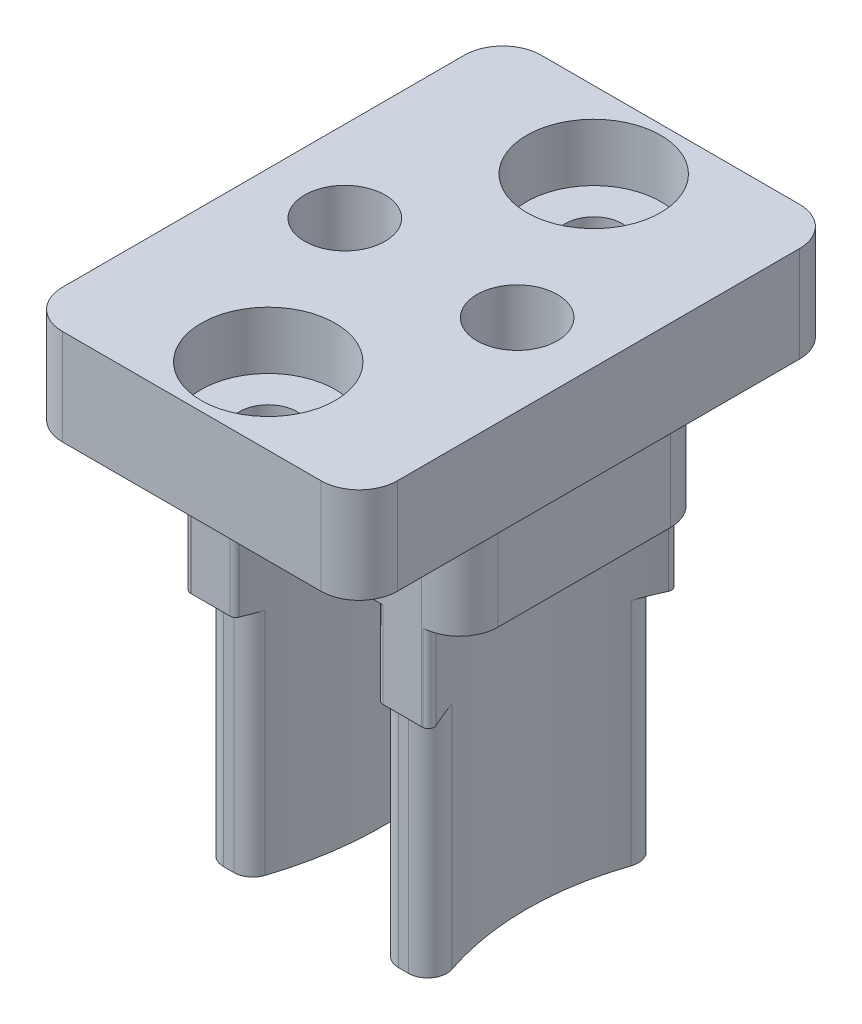
from build123d import *

# Parameters (mm, degrees)
SKETCH1_W           = 123.5
SKETCH1_H           = 81.5
BOSS_EXTRUDE1_DEPTH = 8
CHAMFER1_SIZE       = 10
SKETCH2_W           = 130
SKETCH2_H           = 88
BOSS_EXTRUDE2_DEPTH = 9
FILLET1_R           = 2
SKETCH3_W           = 124
SKETCH3_H           = 82
CUT_EXTRUDE1_DEPTH  = 2
FILLET2_R           = 2
SKETCH4_R           = 10
CUT_EXTRUDE2_DEPTH  = 18
SKETCH5_R           = 17
SKETCH5_R_2         = 14.5
BOSS_EXTRUDE3_DEPTH = 16.5
SKETCH6_W           = 170
SKETCH6_H           = 36.5
SKETCH6_W_2         = 114
SKETCH6_H_2         = 12
CUT_EXTRUDE3_DEPTH  = 12
FILLET3_R           = 1
SKETCH7_R           = 0.85
CUT_EXTRUDE4_DEPTH  = 20.75
SKETCH11_W          = 130
SKETCH11_H          = 10
CUT_EXTRUDE8_DEPTH  = 85.75
SKETCH13_R          = 2.1
CUT_EXTRUDE9_DEPTH  = 6
SKETCH15_R          = 2.1
SKETCH15_R_2        = 10
BOSS_EXTRUDE4_DEPTH = 3
SKETCH16_W          = 167.35282603
SKETCH16_H          = 111.231485579
SKETCH16_W_2        = 17.5
SKETCH16_H_2        = 25
CUT_EXTRUDE10_DEPTH = 27.5
CUT_EXTRUDE11_START = -5
SKETCH17_W          = 17.5
SKETCH17_H          = 25
SKETCH17_W_2        = 16
SKETCH17_H_2        = 13
CUT_EXTRUDE11_DEPTH = 22.5
FILLET4_R           = 2
SKETCH18_R          = 1.5
CUT_EXTRUDE12_DEPTH = 10
SKETCH19_R          = 3.5
CUT_EXTRUDE13_DEPTH = 3
FILLET5_R           = 0.3


with BuildPart() as part:
    # Sketch1 → Boss-Extrude1 (new body)
    with BuildSketch(Plane(origin=(0, 0, 0), x_dir=(1, 0, 0), z_dir=(0, 1, 0))):
        with Locations((61.75, -40.75)):
            Rectangle(SKETCH1_W, SKETCH1_H)
    extrude(amount=BOSS_EXTRUDE1_DEPTH)

    # Chamfer1
    chamfer1_edges = [part.edges().sort_by_distance(p)[0] for p in [
        (123.5, 4, 0),
        (123.5, 4, 81.5),
    ]]
    chamfer(chamfer1_edges, length=CHAMFER1_SIZE)

    # Sketch2 → Boss-Extrude2 (add)
    with BuildSketch(Plane.XZ):
        with Locations((61.75, 40.75)):
            Rectangle(SKETCH2_W, SKETCH2_H)
    extrude(amount=BOSS_EXTRUDE2_DEPTH)

    # Fillet1
    fillet1_edges = [part.edges().sort_by_distance(p)[0] for p in [
        (113.5, 4, 0),
        (123.5, 4, 71.5),
        (123.5, 4, 10),
        (113.5, 4, 81.5),
        (-3.25, -4.5, 84.75),
        (-3.25, -4.5, -3.25),
        (126.75, -4.5, -3.25),
        (126.75, -4.5, 84.75),
        (0, 4, 0),
        (0, 4, 81.5),
    ]]
    fillet(fillet1_edges, radius=FILLET1_R)

    # Sketch3 → Cut-Extrude1 (cut)
    with BuildSketch(Plane.XZ.offset(9)):
        with Locations((61.75, 40.75)):
            Rectangle(SKETCH3_W, SKETCH3_H)
    extrude(amount=-CUT_EXTRUDE1_DEPTH, mode=Mode.SUBTRACT)

    # Fillet2
    fillet2_edges = [part.edges().sort_by_distance(p)[0] for p in [
        (-0.25, -8, -0.25),
        (-0.25, -8, 81.75),
        (123.75, -8, 81.75),
        (123.75, -8, -0.25),
    ]]
    fillet(fillet2_edges, radius=FILLET2_R)

    # Sketch4 → Cut-Extrude2 (cut, through all)
    with BuildSketch(Plane(origin=(0, 8, 0), x_dir=(1, 0, 0), z_dir=(0, 1, 0))):
        with Locations((22.5, -20.85)):
            Circle(SKETCH4_R)
        with Locations((61.5, -20.85)):
            Circle(SKETCH4_R)
        with Locations((100.5, -20.85)):
            Circle(SKETCH4_R)
        with Locations((100.5, -60.65)):
            Circle(SKETCH4_R)
        with Locations((61.5, -60.65)):
            Circle(SKETCH4_R)
        with Locations((22.5, -60.65)):
            Circle(SKETCH4_R)
    extrude(amount=-CUT_EXTRUDE2_DEPTH, mode=Mode.SUBTRACT)

    # Sketch5 → Boss-Extrude3 (add)
    with BuildSketch(Plane.XZ.offset(7)):
        with Locations((22.5, 60.65)):
            Circle(SKETCH5_R)
        with Locations((22.5, 60.65)):
            Circle(SKETCH5_R_2, mode=Mode.SUBTRACT)
        with Locations((61.5, 60.65)):
            Circle(SKETCH5_R)
        with Locations((61.5, 60.65)):
            Circle(SKETCH5_R_2, mode=Mode.SUBTRACT)
        with Locations((100.5, 60.65)):
            Circle(SKETCH5_R)
        with Locations((100.5, 60.65)):
            Circle(SKETCH5_R_2, mode=Mode.SUBTRACT)
        with Locations((100.5, 20.85)):
            Circle(SKETCH5_R)
        with Locations((100.5, 20.85)):
            Circle(SKETCH5_R_2, mode=Mode.SUBTRACT)
        with Locations((61.5, 20.85)):
            Circle(SKETCH5_R)
        with Locations((61.5, 20.85)):
            Circle(SKETCH5_R_2, mode=Mode.SUBTRACT)
        with Locations((22.5, 20.85)):
            Circle(SKETCH5_R)
        with Locations((22.5, 20.85)):
            Circle(SKETCH5_R_2, mode=Mode.SUBTRACT)
    extrude(amount=BOSS_EXTRUDE3_DEPTH)

    # Sketch6 → Cut-Extrude3 (cut)
    with BuildSketch(Plane.XZ.offset(23.5)):
        with Locations((61.5, 20.85)):
            Rectangle(SKETCH6_W, SKETCH6_H)
        with Locations((61.5, 20.85)):
            Rectangle(SKETCH6_W_2, SKETCH6_H_2, mode=Mode.SUBTRACT)
        with Locations((61.5, 60.65)):
            Rectangle(SKETCH6_W, SKETCH6_H)
        with Locations((61.5, 60.65)):
            Rectangle(SKETCH6_W_2, SKETCH6_H_2, mode=Mode.SUBTRACT)
    extrude(amount=-CUT_EXTRUDE3_DEPTH, mode=Mode.SUBTRACT)

    # Fillet3
    fillet3_edges = [part.edges().sort_by_distance(p)[0] for p in [
        (87.299621218, -17.5, 66.65),
        (113.700378782, -17.5, 66.65),
        (113.700378782, -17.5, 54.65),
        (87.299621218, -17.5, 54.65),
        (9.299621218, -17.5, 54.65),
        (35.700378782, -17.5, 54.65),
        (6.594026279, -17.5, 54.65),
        (48.299621218, -17.5, 54.65),
        (74.700378782, -17.5, 54.65),
        (38.405973721, -17.5, 54.65),
        (45.594026279, -17.5, 54.65),
        (77.405973721, -17.5, 54.65),
        (84.594026279, -17.5, 54.65),
        (35.700378782, -17.5, 66.65),
        (9.299621218, -17.5, 66.65),
        (38.405973721, -17.5, 66.65),
        (45.594026279, -17.5, 66.65),
        (74.700378782, -17.5, 66.65),
        (48.299621218, -17.5, 66.65),
        (77.405973721, -17.5, 66.65),
        (84.594026279, -17.5, 66.65),
        (116.405973721, -17.5, 66.65),
        (116.405973721, -17.5, 54.65),
        (6.594026279, -17.5, 66.65),
        (35.700378782, -17.5, 14.85),
        (9.299621218, -17.5, 14.85),
        (9.299621218, -17.5, 26.85),
        (35.700378782, -17.5, 26.85),
        (113.700378782, -17.5, 26.85),
        (87.299621218, -17.5, 26.85),
        (116.405973721, -17.5, 26.85),
        (74.700378782, -17.5, 26.85),
        (48.299621218, -17.5, 26.85),
        (84.594026279, -17.5, 26.85),
        (77.405973721, -17.5, 26.85),
        (45.594026279, -17.5, 26.85),
        (38.405973721, -17.5, 26.85),
        (87.299621218, -17.5, 14.85),
        (113.700378782, -17.5, 14.85),
        (84.594026279, -17.5, 14.85),
        (77.405973721, -17.5, 14.85),
        (48.299621218, -17.5, 14.85),
        (74.700378782, -17.5, 14.85),
        (45.594026279, -17.5, 14.85),
        (38.405973721, -17.5, 14.85),
        (6.594026279, -17.5, 14.85),
        (6.594026279, -17.5, 26.85),
        (116.405973721, -17.5, 14.85),
    ]]
    fillet(fillet3_edges, radius=FILLET3_R)

    # Sketch7 → Cut-Extrude4 (cut)
    with BuildSketch(Plane.XZ.offset(23.5)):
        with Locations((6.75, 20.85)):
            Circle(SKETCH7_R)
        with Locations((38.25, 20.85)):
            Circle(SKETCH7_R)
        with Locations((45.75, 20.85)):
            Circle(SKETCH7_R)
        with Locations((77.25, 20.85)):
            Circle(SKETCH7_R)
        with Locations((84.75, 20.85)):
            Circle(SKETCH7_R)
        with Locations((116.25, 20.85)):
            Circle(SKETCH7_R)
        with Locations((116.25, 60.65)):
            Circle(SKETCH7_R)
        with Locations((84.75, 60.65)):
            Circle(SKETCH7_R)
        with Locations((77.25, 60.65)):
            Circle(SKETCH7_R)
        with Locations((45.75, 60.65)):
            Circle(SKETCH7_R)
        with Locations((38.25, 60.65)):
            Circle(SKETCH7_R)
        with Locations((6.75, 60.65)):
            Circle(SKETCH7_R)
    extrude(amount=-CUT_EXTRUDE4_DEPTH, mode=Mode.SUBTRACT)

    # Sketch11 → Cut-Extrude8 (cut, through all)
    with BuildSketch(Plane(origin=(0, 0, 0), x_dir=(-1, 0, 0), z_dir=(0, 0, -1))):
        with Locations((-61.75, 5)):
            Rectangle(SKETCH11_W, SKETCH11_H)
    extrude(amount=-CUT_EXTRUDE8_DEPTH, mode=Mode.SUBTRACT)

    # Sketch13 → Cut-Extrude9 (cut)
    with BuildSketch(Plane(origin=(0, 0, 0), x_dir=(1, 0, 0), z_dir=(0, 1, 0))):
        with Locations((116.25, -60.65)):
            Circle(SKETCH13_R)
        with Locations((85.5, -60.65)):
            Circle(SKETCH13_R)
        with Locations((76.5, -60.65)):
            Circle(SKETCH13_R)
        with Locations((116.25, -20.85)):
            Circle(SKETCH13_R)
        with Locations((85.5, -20.85)):
            Circle(SKETCH13_R)
        with Locations((76.5, -20.85)):
            Circle(SKETCH13_R)
        with Locations((46.5, -20.85)):
            Circle(SKETCH13_R)
        with Locations((37.5, -20.85)):
            Circle(SKETCH13_R)
        with Locations((6.75, -20.85)):
            Circle(SKETCH13_R)
        with Locations((6.75, -60.65)):
            Circle(SKETCH13_R)
        with Locations((37.5, -60.65)):
            Circle(SKETCH13_R)
        with Locations((46.5, -60.65)):
            Circle(SKETCH13_R)
    extrude(amount=-CUT_EXTRUDE9_DEPTH, mode=Mode.SUBTRACT)

    # Sketch15 → Boss-Extrude4 (add)
    with BuildSketch(Plane(origin=(0, 0, 0), x_dir=(1, 0, 0), z_dir=(0, 1, 0))):
        with BuildLine():
            Line((126.75, -82.75), (126.75, 1.25))
            ThreePointArc((126.75, 1.25), (126.164213562, 2.664213562), (124.75, 3.25))
            Line((124.75, 3.25), (-1.25, 3.25))
            ThreePointArc((-1.25, 3.25), (-2.664213562, 2.664213562), (-3.25, 1.25))
            Line((-3.25, 1.25), (-3.25, -82.75))
            ThreePointArc((-3.25, -82.75), (-2.664213562, -84.164213562), (-1.25, -84.75))
            Line((-1.25, -84.75), (124.75, -84.75))
            ThreePointArc((124.75, -84.75), (126.164213562, -84.164213562), (126.75, -82.75))
        make_face()
        with Locations((6.75, -60.65)):
            Circle(SKETCH15_R, mode=Mode.SUBTRACT)
        with Locations((22.5, -60.65)):
            Circle(SKETCH15_R_2, mode=Mode.SUBTRACT)
        with Locations((37.5, -60.65)):
            Circle(SKETCH15_R, mode=Mode.SUBTRACT)
        with Locations((46.5, -60.65)):
            Circle(SKETCH15_R, mode=Mode.SUBTRACT)
        with Locations((61.5, -60.65)):
            Circle(SKETCH15_R_2, mode=Mode.SUBTRACT)
        with Locations((76.5, -60.65)):
            Circle(SKETCH15_R, mode=Mode.SUBTRACT)
        with Locations((100.5, -60.65)):
            Circle(SKETCH15_R_2, mode=Mode.SUBTRACT)
        with Locations((116.25, -60.65)):
            Circle(SKETCH15_R, mode=Mode.SUBTRACT)
        with Locations((116.25, -20.85)):
            Circle(SKETCH15_R, mode=Mode.SUBTRACT)
        with Locations((100.5, -20.85)):
            Circle(SKETCH15_R_2, mode=Mode.SUBTRACT)
        with Locations((85.5, -20.85)):
            Circle(SKETCH15_R, mode=Mode.SUBTRACT)
        with Locations((76.5, -20.85)):
            Circle(SKETCH15_R, mode=Mode.SUBTRACT)
        with Locations((61.5, -20.85)):
            Circle(SKETCH15_R_2, mode=Mode.SUBTRACT)
        with Locations((46.5, -20.85)):
            Circle(SKETCH15_R, mode=Mode.SUBTRACT)
        with Locations((37.5, -20.85)):
            Circle(SKETCH15_R, mode=Mode.SUBTRACT)
        with Locations((22.5, -20.85)):
            Circle(SKETCH15_R_2, mode=Mode.SUBTRACT)
        with Locations((85.5, -60.65)):
            Circle(SKETCH15_R, mode=Mode.SUBTRACT)
        with Locations((6.75, -20.85)):
            Circle(SKETCH15_R, mode=Mode.SUBTRACT)
    extrude(amount=BOSS_EXTRUDE4_DEPTH)

    # Sketch16 → Cut-Extrude10 (cut, through all)
    with BuildSketch(Plane(origin=(0, 3, 0), x_dir=(1, 0, 0), z_dir=(0, 1, 0))):
        with Locations((62.017342261, -41.761195324)):
            Rectangle(SKETCH16_W, SKETCH16_H)
        with Locations((81, -60.65)):
            Rectangle(SKETCH16_W_2, SKETCH16_H_2, mode=Mode.SUBTRACT)
    extrude(amount=-CUT_EXTRUDE10_DEPTH, mode=Mode.SUBTRACT)

    # Sketch17 → Cut-Extrude11 (cut, through all)
    with BuildSketch(Plane(origin=(0, 3, 0), x_dir=(1, 0, 0), z_dir=(0, 1, 0)).offset(CUT_EXTRUDE11_START)):
        with Locations((81, -60.65)):
            Rectangle(SKETCH17_W, SKETCH17_H)
        with Locations((81, -60.65)):
            Rectangle(SKETCH17_W_2, SKETCH17_H_2, mode=Mode.SUBTRACT)
    extrude(amount=-CUT_EXTRUDE11_DEPTH, mode=Mode.SUBTRACT)

    # Fillet4
    fillet4_edges = [part.edges().sort_by_distance(p)[0] for p in [
        (72.25, 0.5, 73.15),
        (89.75, 0.5, 73.15),
        (73, -4.5, 54.15),
        (89, -4.5, 54.15),
        (72.25, 0.5, 48.15),
        (89.75, 0.5, 48.15),
        (73, -4.5, 67.15),
        (89, -4.5, 67.15),
    ]]
    fillet(fillet4_edges, radius=FILLET4_R)

    # Sketch18 → Cut-Extrude12 (cut)
    with BuildSketch(Plane(origin=(0, 3, 0), x_dir=(1, 0, 0), z_dir=(0, 1, 0))):
        with Locations((81, -52.15)):
            Circle(SKETCH18_R)
        with Locations((81, -69.15)):
            Circle(SKETCH18_R)
    extrude(amount=-CUT_EXTRUDE12_DEPTH, mode=Mode.SUBTRACT)

    # Sketch19 → Cut-Extrude13 (cut)
    with BuildSketch(Plane(origin=(0, 3, 0), x_dir=(1, 0, 0), z_dir=(0, 1, 0))):
        with Locations((81, -52.15)):
            Circle(SKETCH19_R)
        with Locations((81, -69.15)):
            Circle(SKETCH19_R)
    extrude(amount=-CUT_EXTRUDE13_DEPTH, mode=Mode.SUBTRACT)

    # Fillet5
    fillet5_edges = [part.edges().sort_by_distance(p)[0] for p in [
        (77.208278072, -9.25, 67.15),
        (84.791721928, -9.25, 67.15),
        (84.791721928, -9.25, 54.15),
        (77.208278072, -9.25, 54.15),
        (74.493918477, -9.25, 54.215088764),
        (74.493918477, -9.25, 67.084911236),
        (87.506081523, -9.25, 54.215088764),
        (87.506081523, -9.25, 67.084911236),
    ]]
    fillet(fillet5_edges, radius=FILLET5_R)


solid = part.part
